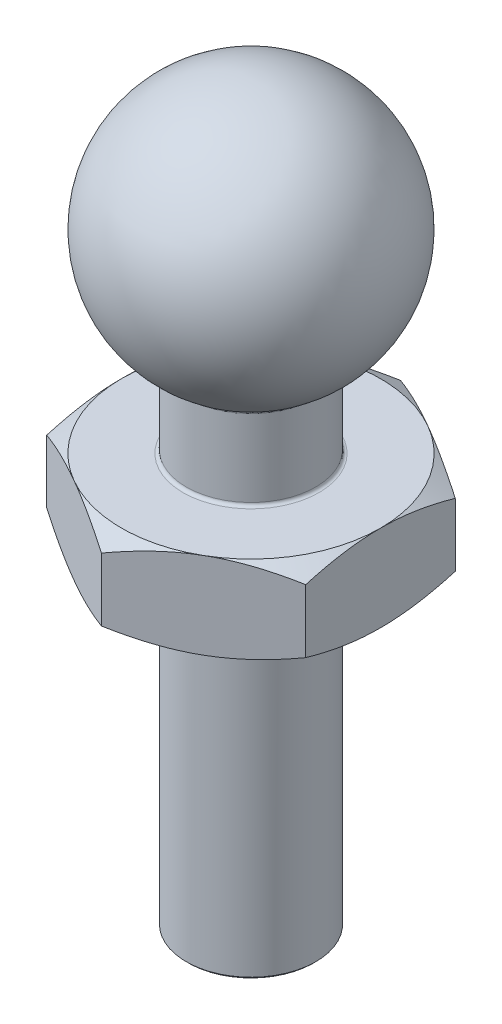
from build123d import *

# Parameters (mm, degrees)
CHAMFER1_SIZE       = 0.05
BOSS_EXTRUDE1_DEPTH = 2
SKETCH6_OUTSIDE_W   = 18.79
SKETCH6_OUTSIDE_H   = 19.718
SKETCH6_OUTSIDE_R   = 3
CUT_EXTRUDE1_DEPTH  = 2
CUT_EXTRUDE1_TAPER  = 60
SKETCH7_OUTSIDE_W   = 18.79
SKETCH7_OUTSIDE_H   = 19.718
SKETCH7_OUTSIDE_R   = 3
CUT_EXTRUDE2_DEPTH  = 2
CUT_EXTRUDE2_TAPER  = 60
FILLET1_R           = 0.075


with BuildPart() as part:
    # Sketch1 → Revolve1 (revolve)
    with BuildSketch(Plane.XY):
        with BuildLine():
            Line((0, 0), (1.5, 0))
            Line((1.5, 0), (1.5, 11.401923789))
            ThreePointArc((1.5, 11.401923789), (2.897777479, 14.776457135), (0, 17))
            Line((0, 17), (0, 11))
            Line((0, 11), (0, 0))
        make_face()
    revolve(axis=Axis((0, 0, 0), (0, 1, 0)))

    # Chamfer1
    chamfer1_edges = [part.edges().sort_by_distance(p)[0] for p in [
        (-1.5, 0, 0),
    ]]
    chamfer(chamfer1_edges, length=CHAMFER1_SIZE)

    # Sketch4 → Boss-Extrude1 (add)
    with BuildSketch(Plane(origin=(0, 7.5, 0), x_dir=(1, 0, 0), z_dir=(0, 1, 0))):
        Polygon((3, -1.732050808), (3, 1.732050808), (0, 3.464101615), (-3, 1.732050808), (-3, -1.732050808), (0, -3.464101615), align=None)
    extrude(amount=BOSS_EXTRUDE1_DEPTH)

    # Sketch6 outside → Cut-Extrude1 (cut)
    with BuildSketch(Plane.XZ.offset(-7.5)):
        Rectangle(SKETCH6_OUTSIDE_W, SKETCH6_OUTSIDE_H)
        Circle(SKETCH6_OUTSIDE_R, mode=Mode.SUBTRACT)
    extrude(amount=-CUT_EXTRUDE1_DEPTH, taper=CUT_EXTRUDE1_TAPER, mode=Mode.SUBTRACT)

    # Sketch7 outside → Cut-Extrude2 (cut)
    with BuildSketch(Plane(origin=(0, 9.5, 0), x_dir=(1, 0, 0), z_dir=(0, 1, 0))):
        Rectangle(SKETCH7_OUTSIDE_W, SKETCH7_OUTSIDE_H)
        Circle(SKETCH7_OUTSIDE_R, mode=Mode.SUBTRACT)
    extrude(amount=-CUT_EXTRUDE2_DEPTH, taper=CUT_EXTRUDE2_TAPER, mode=Mode.SUBTRACT)

    # Fillet1
    fillet1_edges = [part.edges().sort_by_distance(p)[0] for p in [
        (-1.5, 9.5, 0),
        (-1.5, 11.401923789, 0),
    ]]
    fillet(fillet1_edges, radius=FILLET1_R)


solid = part.part
